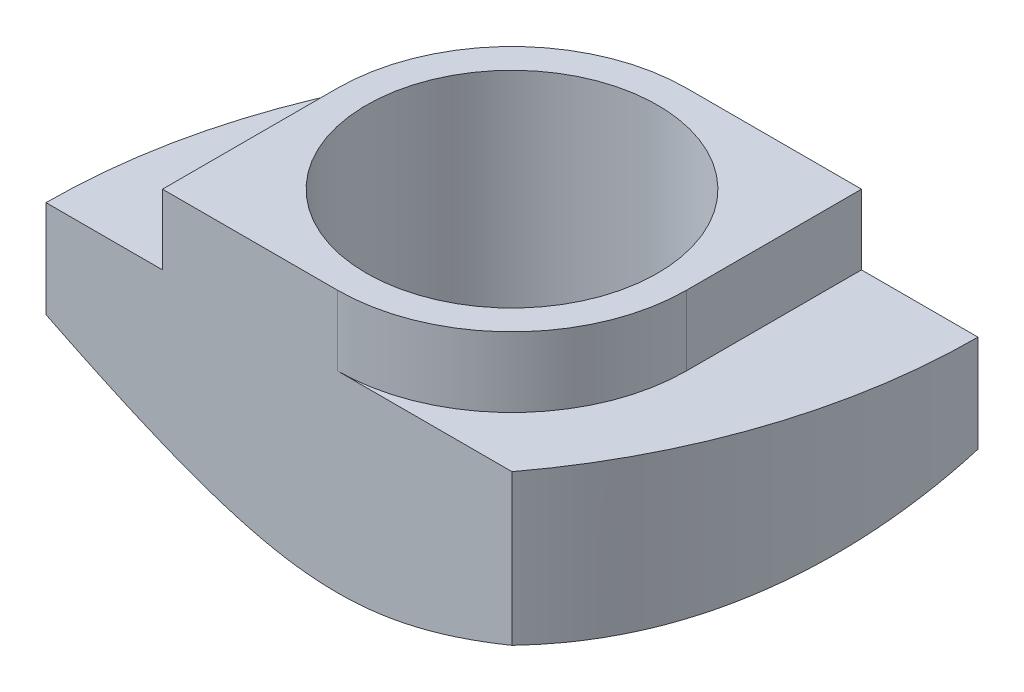
from build123d import *

# Parameters (mm, degrees)
SKETCH_1_W          = 10
SKETCH_1_H          = 6
SKETCH_1_R          = 2.5
EXTRUDE_1_DEPTH     = 3.3
SKETCH_2_R          = 2.5
EXTRUDE_2_DEPTH     = 1.2
CUT_EXTRUDE_1_DEPTH = 5.5


with BuildPart() as part:
    # 草图1 → 凸台-拉伸1 (new body)
    with BuildSketch(Plane(origin=(0, 0, 0), x_dir=(1, 0, 0), z_dir=(0, 1, 0))):
        with Locations((5, 3)):
            Rectangle(SKETCH_1_W, SKETCH_1_H)
        with Locations((5, 3)):
            Circle(SKETCH_1_R, mode=Mode.SUBTRACT)
    extrude(amount=EXTRUDE_1_DEPTH)

    # 草图2 → 凸台-拉伸2 (add)
    with BuildSketch(Plane(origin=(0, 3.3, 0), x_dir=(1, 0, 0), z_dir=(0, 1, 0))):
        with BuildLine():
            Line((2, 3), (2, 0))
            Line((2, 0), (5, 0))
            ThreePointArc((5, 0), (7.121320344, 0.878679656), (8, 3))
            Line((8, 3), (8, 6))
            Line((8, 6), (5, 6))
            ThreePointArc((5, 6), (2.878679656, 5.121320344), (2, 3))
        make_face()
        with Locations((5, 3)):
            Circle(SKETCH_2_R, mode=Mode.SUBTRACT)
    extrude(amount=EXTRUDE_2_DEPTH)

    # 草图3 → 切除-拉伸1 (cut, through all)
    with BuildSketch(Plane(origin=(0, 0, 0), x_dir=(1, 0, 0), z_dir=(0, 1, 0))):
        with BuildLine():
            Line((2, 6), (0, 6))
            Line((0, 6), (0, 0))
            ThreePointArc((0, 0), (0.513167019, 3.16227766), (2, 6))
        make_face()
        with BuildLine():
            Line((10, 0), (10, 6))
            ThreePointArc((10, 6), (9.486832981, 2.83772234), (8, 0))
            Line((8, 0), (10, 0))
        make_face()
    extrude(amount=CUT_EXTRUDE_1_DEPTH, mode=Mode.SUBTRACT)

    # 草图4 one side → 切除-旋转1 (revolve, cut)
    with BuildSketch(Plane(origin=(-3, 0, -3), x_dir=(1, 0, 0), z_dir=(0, 0, 1))):
        Polygon((16, 0), (16, 2.886751346), (11, 0), align=None)
    revolve(axis=Axis((5, 3.3, -3), (0, -1, 0)), mode=Mode.SUBTRACT)


solid = part.part
